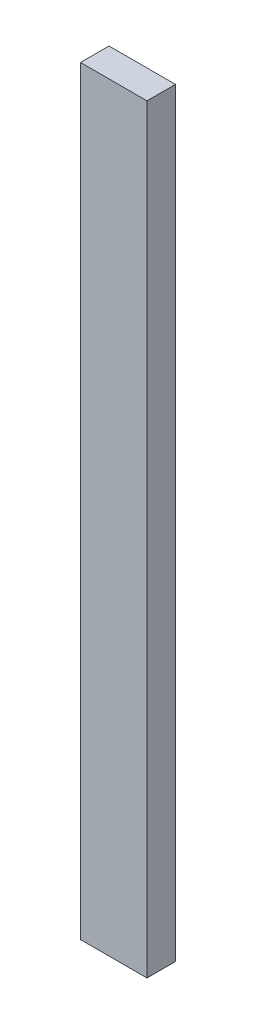
from build123d import *

# Parameters (mm, degrees)
SKETCH1_W           = 7
SKETCH1_H           = 3
BOSS_EXTRUDE1_DEPTH = 80


with BuildPart() as part:
    # Sketch1 → Boss-Extrude1 (new body)
    with BuildSketch(Plane(origin=(0, 0, 0), x_dir=(1, 0, 0), z_dir=(0, 1, 0))):
        with Locations((20.388493549, -6.198538177)):
            Rectangle(SKETCH1_W, SKETCH1_H)
    extrude(amount=BOSS_EXTRUDE1_DEPTH)


solid = part.part
